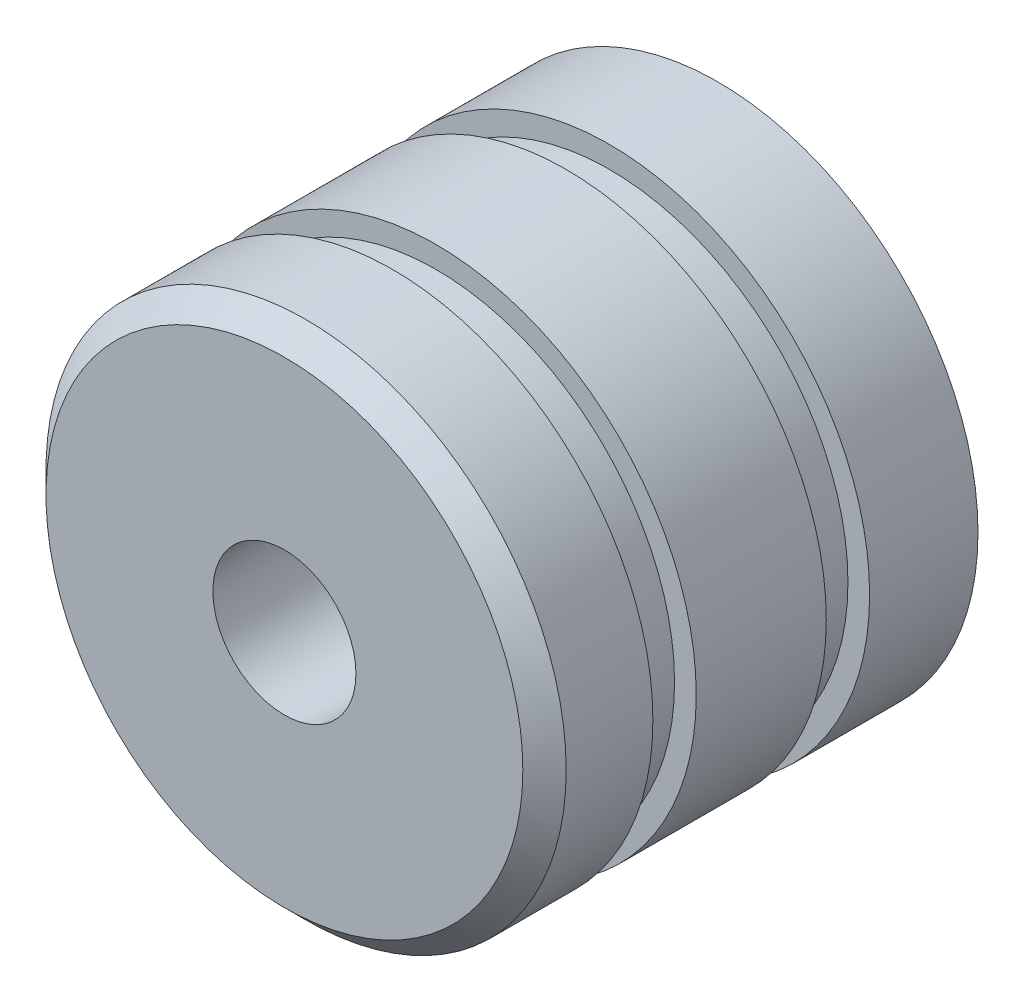
from build123d import *

# Parameters (mm, degrees)
SKETCH1_R                 = 6
BOSS_EXTRUDE1_DEPTH       = 5
CUT_EXTRUDE1_START        = -2.5
SKETCH2_R                 = 6
SKETCH2_R_2               = 5.5
CUT_EXTRUDE1_DEPTH        = 1
CHAMFER1_SIZE             = 0.5
M4X0_7_TAPPED_HOLE1_D     = 3.3
M4X0_7_TAPPED_HOLE1_DEPTH = 8
M4X0_7_TAPPED_HOLE1_TIP   = 0.991420021


with BuildPart() as part:
    # Sketch1 → Boss-Extrude1 (new body, symmetric)
    with BuildSketch(Plane.XY):
        Circle(SKETCH1_R)
    extrude(amount=BOSS_EXTRUDE1_DEPTH, both=True)

    # Sketch2 → Cut-Extrude1 (cut)
    with BuildSketch(Plane.XY.offset(5).offset(CUT_EXTRUDE1_START)):
        Circle(SKETCH2_R)
        Circle(SKETCH2_R_2, mode=Mode.SUBTRACT)
    cut_extrude1 = extrude(amount=-CUT_EXTRUDE1_DEPTH, mode=Mode.SUBTRACT)

    # Mirror1: Cut-Extrude1 across plane
    add(cut_extrude1.mirror(Plane.XY), mode=Mode.SUBTRACT)

    # Chamfer1
    chamfer1_edges = [part.edges().sort_by_distance(p)[0] for p in [
        (-6, 0, 5),
    ]]
    chamfer(chamfer1_edges, length=CHAMFER1_SIZE)

    # M4x0.7 Tapped Hole1
    with Locations(Plane.XY.offset(5)):
        with Locations((0, 0)):
            Hole(M4X0_7_TAPPED_HOLE1_D / 2, depth=M4X0_7_TAPPED_HOLE1_DEPTH)
            with Locations((0, 0, -(M4X0_7_TAPPED_HOLE1_DEPTH + M4X0_7_TAPPED_HOLE1_TIP / 2))):  # 118° drill point
                Cone(0, M4X0_7_TAPPED_HOLE1_D / 2, M4X0_7_TAPPED_HOLE1_TIP, mode=Mode.SUBTRACT)


solid = part.part
